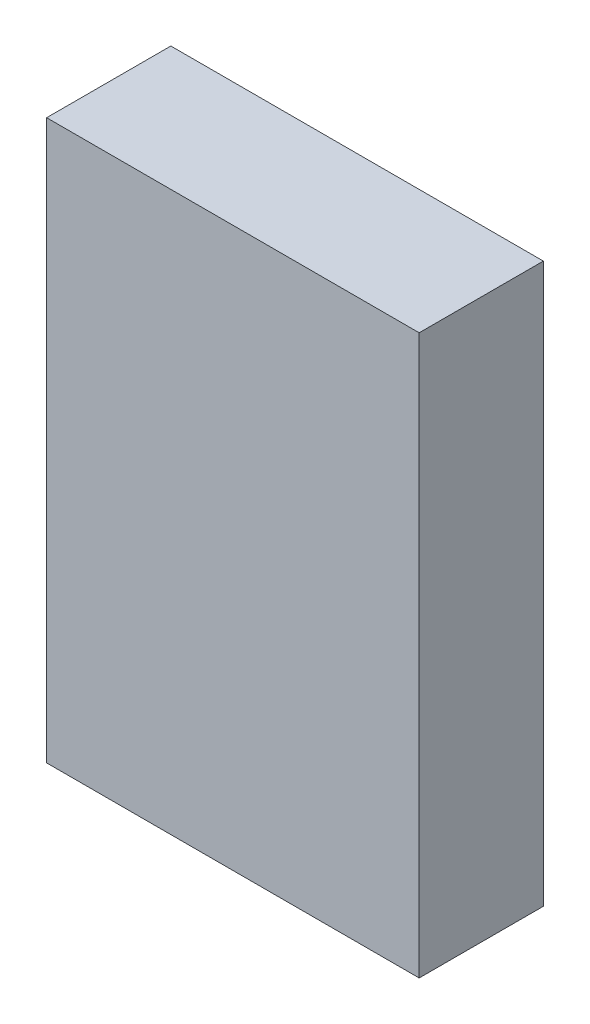
from build123d import *

# Parameters (mm, degrees)
ESQUISSE1_W        = 60
ESQUISSE1_H        = 90
BOSS_EXTRU_1_DEPTH = 20


with BuildPart() as part:
    # Esquisse1 → Boss.-Extru.1 (new body)
    with BuildSketch(Plane.XY):
        with Locations((30, 45)):
            Rectangle(ESQUISSE1_W, ESQUISSE1_H)
    extrude(amount=BOSS_EXTRU_1_DEPTH)


solid = part.part
